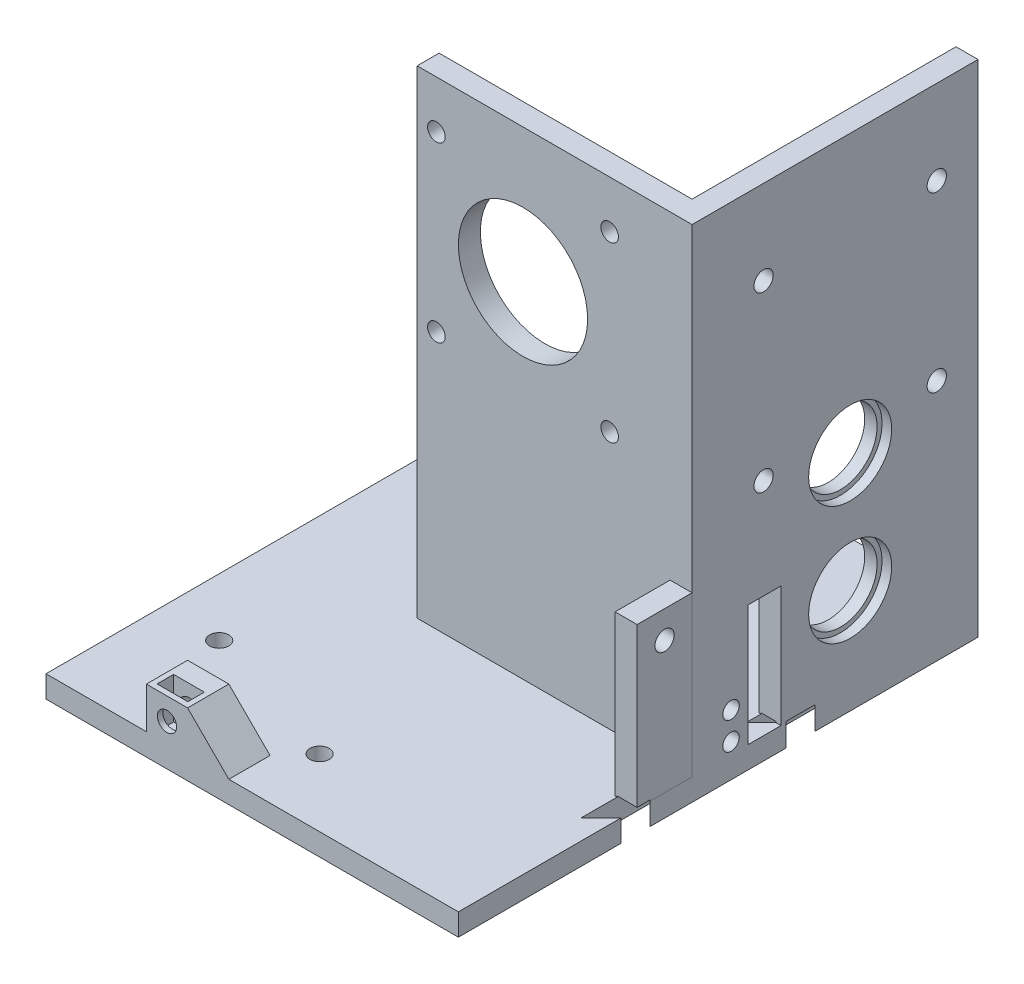
from build123d import *

# Parameters (mm, degrees)
SKETCH17_W                       = 75
SKETCH17_H                       = 94.5
BASE_DEPTH                       = 4
SKETCH18_W                       = 50
SKETCH18_H                       = 4
XWALL_DEPTH                      = 87
SKETCH19_W                       = 4
SKETCH19_H                       = 48
YWALL_DEPTH                      = 87
SKETCH4_R                        = 1.6
SKETCH4_R_2                      = 11.75
XMOTORHOLES_DEPTH                = 5
SKETCH14_R                       = 6.65
BEARINGINNERHOLE_DEPTH           = 5
SKETCH15_R                       = 7.55
BEARINGOUTERHOLE_DEPTH           = 1.75
SKETCH20_R                       = 1.75
SIDE_CONNECTOR_SCREW_HOLES_DEPTH = 4
SKETCH22_W                       = 10
SKETCH22_H                       = 29
SKETCH22_R                       = 1.75
SIDE_MOUNT_BODY_DEPTH            = 4
DOVETAILS_DEPTH                  = 4.2
BACK_LEFT_CASE_SCREW_BODY_DEPTH  = 5
SKETCH33_R                       = 1.75
BACK_LEFT_CASE_SCREW_HOLE_DEPTH  = 9
SKETCH34_W                       = 5.6
SKETCH34_H                       = 3
BACK_LEFT_CASE_NUT_HOLE_DEPTH    = 7.5
FRONT_EFT_CASE_SCREW_BODY_DEPTH  = 7.5
SKETCH36_R                       = 1.75
FRONT_LEFT_CASE_SCREW_HOLE_DEPTH = 7.5
SKETCH37_W                       = 5.6
SKETCH37_H                       = 3
FRONT_LEFT_CASE_NUT_HOLE_DEPTH   = 7.5
SKETCH38_R                       = 1.75
FOOT_HOLES_DEPTH                 = 10
SKETCH39_R                       = 1.5
SKETCH39_W                       = 6
SKETCH39_H                       = 22
MOTOR_CABLE_PASSTHROUGH_DEPTH    = 4
SKETCH40_R                       = 1.75
ELECTRONICS_MOUNT_HOLES_DEPTH    = 4


with BuildPart() as part:
    # Sketch17 → Base (new body)
    with BuildSketch(Plane(origin=(0, 0, 0), x_dir=(1, 0, 0), z_dir=(0, 1, 0))):
        with Locations((-37.5, -47.25)):
            Rectangle(SKETCH17_W, SKETCH17_H)
    extrude(amount=BASE_DEPTH)

    # Sketch18 → XWall (add)
    with BuildSketch(Plane(origin=(0, 4, 0), x_dir=(1, 0, 0), z_dir=(0, 1, 0))):
        with Locations((-25, -50)):
            Rectangle(SKETCH18_W, SKETCH18_H)
    extrude(amount=XWALL_DEPTH)

    # Sketch19 → YWall (add)
    with BuildSketch(Plane(origin=(0, 4, 0), x_dir=(1, 0, 0), z_dir=(0, 1, 0))):
        with Locations((-2, -24)):
            Rectangle(SKETCH19_W, SKETCH19_H)
    extrude(amount=YWALL_DEPTH)

    # Sketch4 → XMotorHoles (cut)
    with BuildSketch(Plane.XY.offset(52)):
        with Locations((-15, 82.342994265)):
            Circle(SKETCH4_R)
        with Locations((-46.5, 82.342994265)):
            Circle(SKETCH4_R)
        with Locations((-46.5, 50.842994265)):
            Circle(SKETCH4_R)
        with Locations((-15, 50.842994265)):
            Circle(SKETCH4_R)
        with Locations((-30.75, 66.592994265)):
            Circle(SKETCH4_R_2)
    extrude(amount=-XMOTORHOLES_DEPTH, mode=Mode.SUBTRACT)

    # Sketch14 → BearingInnerHole (cut)
    with BuildSketch(Plane.ZY.offset(4)):
        with Locations((23.25, 19)):
            Circle(SKETCH14_R)
        with Locations((23.25, 40.65)):
            Circle(SKETCH14_R)
    extrude(amount=-BEARINGINNERHOLE_DEPTH, mode=Mode.SUBTRACT)

    # Sketch15 → BearingOuterHole (cut)
    with BuildSketch(Plane.ZY):
        with Locations((23.25, 19)):
            Circle(SKETCH15_R)
        with Locations((23.25, 40.65)):
            Circle(SKETCH15_R)
    extrude(amount=BEARINGOUTERHOLE_DEPTH, mode=Mode.SUBTRACT)

    # Sketch20 → Side_Connector_Screw_Holes (cut)
    with BuildSketch(Plane.ZY.offset(4)):
        with Locations((7.5, 75.65)):
            Circle(SKETCH20_R)
        with Locations((39, 75.65)):
            Circle(SKETCH20_R)
        with Locations((7.5, 44.15)):
            Circle(SKETCH20_R)
        with Locations((39, 44.15)):
            Circle(SKETCH20_R)
    extrude(amount=-SIDE_CONNECTOR_SCREW_HOLES_DEPTH, mode=Mode.SUBTRACT)


with BuildPart() as body_2:
    # Sketch22 → Side_Mount_Body (new body)
    with BuildSketch(Plane(origin=(0, 0, 0), x_dir=(0, 0, -1), z_dir=(1, 0, 0))):
        with Locations((-57, 18.5)):
            Rectangle(SKETCH22_W, SKETCH22_H)
        with Locations((-57, 28)):
            Circle(SKETCH22_R, mode=Mode.SUBTRACT)
    extrude(amount=-SIDE_MOUNT_BODY_DEPTH)


with BuildPart() as dovetails_tool:
    # Sketch23 → Dovetails (new body)
    with BuildSketch(Plane.XZ):
        Polygon((0.1, 59.708578644), (-3.635533906, 55.973044738), (-3.635533906, 68.526955262), (0.1, 64.791421356), align=None)
        Polygon((0.1, 29.708578644), (0.1, 34.791421356), (-3.635533906, 38.526955262), (-3.635533906, 25.973044738), align=None)
    extrude(amount=-DOVETAILS_DEPTH)


with BuildPart() as part_1:
    add(part.part)

    # Dovetails: cut by dovetails_tool
    add(dovetails_tool.part, mode=Mode.SUBTRACT)

    # Sketch32 → Back_Left_Case_Screw_Body (add)
    with BuildSketch(Plane(origin=(-41.75, 0, 0), x_dir=(1, 0, 0), z_dir=(0, 0, 1))):
        Polygon((-7.5, 11.5), (-15, 11.5), (-15, 4), (0, 4), align=None)
    extrude(amount=BACK_LEFT_CASE_SCREW_BODY_DEPTH)

    # Sketch33 → Back_Left_Case_Screw_Hole (cut)
    with BuildSketch(Plane(origin=(0, 23, 0), x_dir=(-1, 0, 0), z_dir=(0, 0, 1))):
        with Locations((53, 15.5)):
            Circle(SKETCH33_R)
    extrude(amount=BACK_LEFT_CASE_SCREW_HOLE_DEPTH, mode=Mode.SUBTRACT)

    # Sketch34 → Back_Left_Case_Nut_Hole (cut)
    with BuildSketch(Plane(origin=(0, 11.5, 0), x_dir=(1, 0, 0), z_dir=(0, 1, 0))):
        with Locations((-53, -2.5)):
            Rectangle(SKETCH34_W, SKETCH34_H)
    extrude(amount=-BACK_LEFT_CASE_NUT_HOLE_DEPTH, mode=Mode.SUBTRACT)

    # Sketch35 → Front_;eft_Case_Screw_Body (add)
    with BuildSketch(Plane.XY.offset(94.5)):
        Polygon((-56.75, 4), (-56.75, 11.5), (-49.25, 11.5), (-41.75, 4), align=None)
    extrude(amount=-FRONT_EFT_CASE_SCREW_BODY_DEPTH)

    # Sketch36 → Front_Left_Case_Screw_Hole (cut)
    with BuildSketch(Plane.XY.offset(94.5)):
        with Locations((-53, 7.5)):
            Circle(SKETCH36_R)
    extrude(amount=-FRONT_LEFT_CASE_SCREW_HOLE_DEPTH, mode=Mode.SUBTRACT)

    # Sketch37 → Front_Left_Case_Nut_Hole (cut)
    with BuildSketch(Plane(origin=(0, 11.5, 0), x_dir=(1, 0, 0), z_dir=(0, 1, 0))):
        with Locations((-53, -92)):
            Rectangle(SKETCH37_W, SKETCH37_H)
    extrude(amount=-FRONT_LEFT_CASE_NUT_HOLE_DEPTH, mode=Mode.SUBTRACT)

    # Sketch38 → Foot_Holes (cut)
    with BuildSketch(Plane.XZ):
        with Locations((-37.5, 82.25)):
            Circle(SKETCH38_R)
        with Locations((-37.5, 12.25)):
            Circle(SKETCH38_R)
    extrude(amount=-FOOT_HOLES_DEPTH, mode=Mode.SUBTRACT)

    # Sketch39 → Motor_Cable_Passthrough (cut)
    with BuildSketch(Plane.ZY.offset(4)):
        with Locations((44.915, 11)):
            Circle(SKETCH39_R)
        with Locations((44.915, 6)):
            Circle(SKETCH39_R)
        with Locations((38.83, 15)):
            Rectangle(SKETCH39_W, SKETCH39_H)
    extrude(amount=-MOTOR_CABLE_PASSTHROUGH_DEPTH, mode=Mode.SUBTRACT)

    # Sketch40 → Electronics_Mount_Holes (cut)
    with BuildSketch(Plane(origin=(0, 4, 0), x_dir=(1, 0, 0), z_dir=(0, 1, 0))):
        with Locations((-64.5, -13.5)):
            Circle(SKETCH40_R)
        with Locations((-64.5, -73.5)):
            Circle(SKETCH40_R)
    extrude(amount=-ELECTRONICS_MOUNT_HOLES_DEPTH, mode=Mode.SUBTRACT)


with BuildPart() as body_2_1:
    add(body_2.part)

    # Dovetails: cut by dovetails_tool
    add(dovetails_tool.part, mode=Mode.SUBTRACT)


solid = Compound([part_1.part, body_2_1.part])
